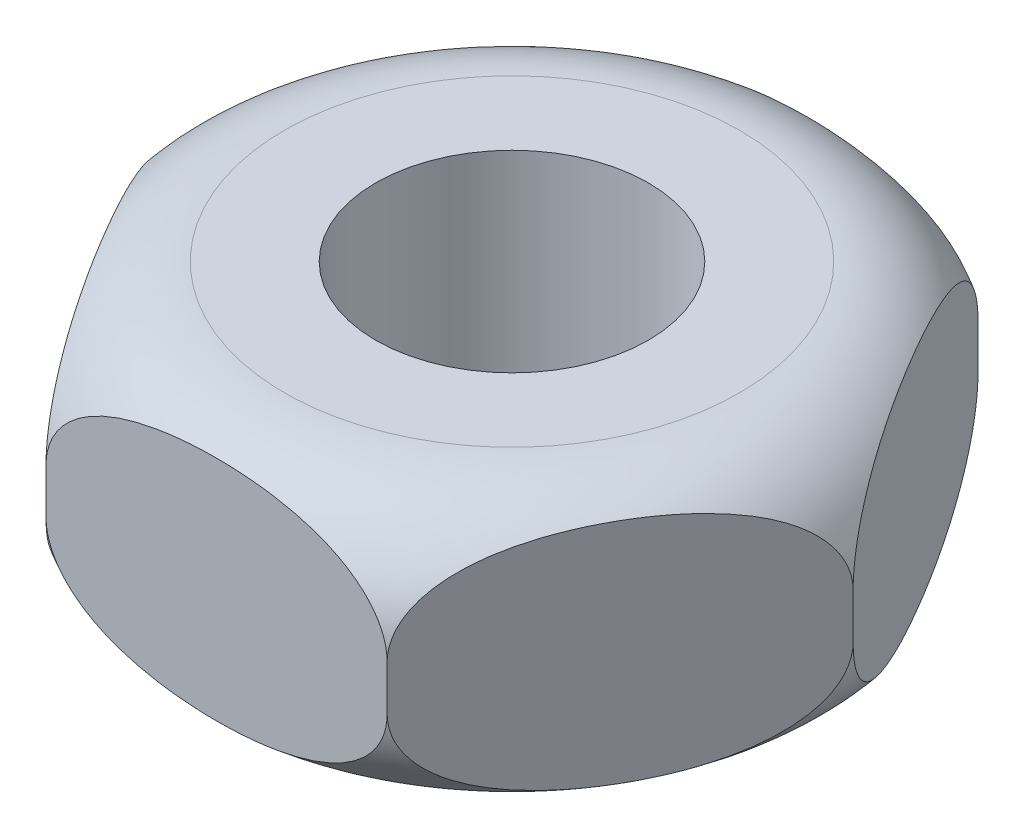
from build123d import *

# Parameters (mm, degrees)
SKETCH1_R           = 6
BOSS_EXTRUDE1_DEPTH = 6


with BuildPart() as part:
    # Sketch1 → Boss-Extrude1 (new body, symmetric)
    with BuildSketch(Plane(origin=(0, 0, 0), x_dir=(1, 0, 0), z_dir=(0, 1, 0))):
        Polygon((15.011106999, 0), (7.505553499, 13), (-7.505553499, 13), (-15.011106999, 0), (-7.505553499, -13), (7.505553499, -13), align=None)
        Circle(SKETCH1_R, mode=Mode.SUBTRACT)
    extrude(amount=BOSS_EXTRUDE1_DEPTH, both=True)

    # Sketch3 → Cut-Revolve1 (revolve, cut)
    with BuildSketch(Plane.XY):
        with BuildLine():
            Line((10.011106999, 6), (15.011106999, 6))
            Line((15.011106999, 6), (15.011106999, 1))
            ThreePointArc((15.011106999, 1), (13.546640905, 4.535533906), (10.011106999, 6))
        make_face()
    cut_revolve1 = revolve(axis=Axis((0, 1.164773658, 0), (0, 1, 0)), mode=Mode.SUBTRACT)

    # Mirror1: Cut-Revolve1 across plane
    add(cut_revolve1.mirror(Plane.ZX), mode=Mode.SUBTRACT)


solid = part.part
